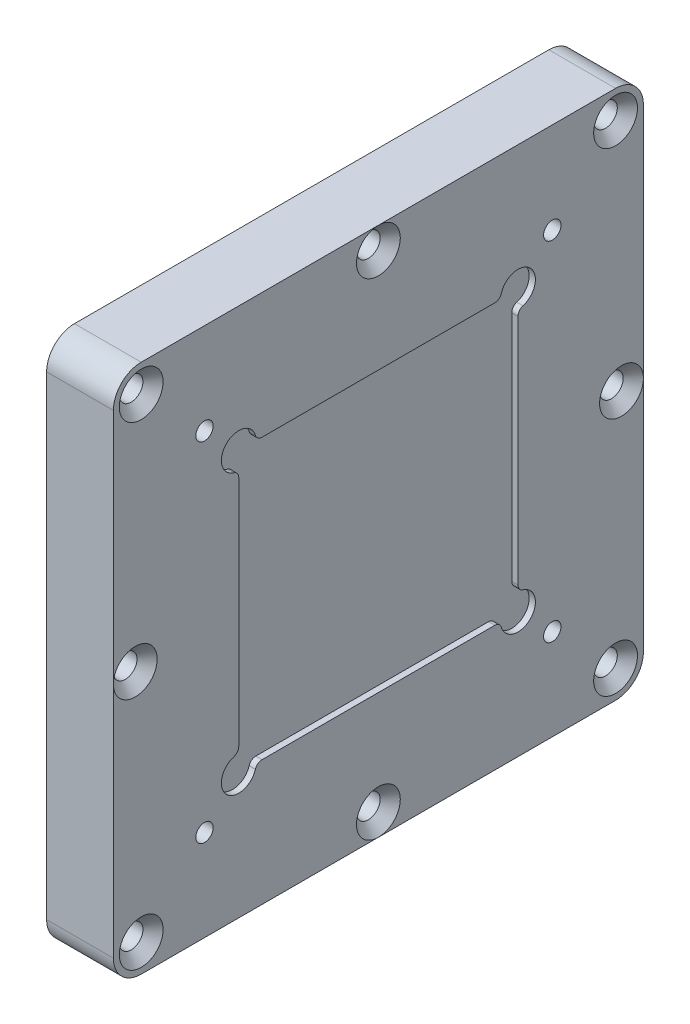
from build123d import *

# Parameters (mm, degrees)
BOSS_EXTRUDE1_DEPTH                             = 9.6
CUT_EXTRUDE1_DEPTH                              = 0.9
FILLET1_R                                       = 1
CSK_FOR_M3_FLAT_HEAD_MACHINE_SCREW1_D           = 3.4
CSK_FOR_M3_FLAT_HEAD_MACHINE_SCREW1_CSINK_D     = 6.3
CSK_FOR_M3_FLAT_HEAD_MACHINE_SCREW1_CSINK_ANGLE = 90
M3X0_5_TAPPED_HOLE1_D                           = 2.5
M3X0_5_TAPPED_HOLE1_DEPTH                       = 7.62
M3X0_5_TAPPED_HOLE1_TIP                         = 0.751075774
M3X0_5_TAPPED_HOLE2_D                           = 2.5
M3X0_5_TAPPED_HOLE2_DEPTH                       = 5.08
M3X0_5_TAPPED_HOLE2_TIP                         = 0.751075774
CUT_EXTRUDE2_DEPTH                              = 6
CHAMFER1_SIZE                                   = 4
FILLET2_R                                       = 1.6


with BuildPart() as part:
    # Sketch2 → Boss-Extrude1 (new body)
    with BuildSketch(Plane(origin=(0, 0, 0), x_dir=(0, 0, -1), z_dir=(1, 0, 0))):
        with BuildLine():
            Line((-34.1, -38.1), (34.1, -38.1))
            ThreePointArc((34.1, -38.1), (36.928427125, -36.928427125), (38.1, -34.1))
            Line((38.1, -34.1), (38.1, 34.1))
            ThreePointArc((38.1, 34.1), (36.928427125, 36.928427125), (34.1, 38.1))
            Line((34.1, 38.1), (-34.1, 38.1))
            ThreePointArc((-34.1, 38.1), (-36.928427125, 36.928427125), (-38.1, 34.1))
            Line((-38.1, 34.1), (-38.1, -34.1))
            ThreePointArc((-38.1, -34.1), (-36.928427125, -36.928427125), (-34.1, -38.1))
        make_face()
    extrude(amount=BOSS_EXTRUDE1_DEPTH)

    # Sketch24 → Cut-Extrude1 (cut)
    with BuildSketch(Plane(origin=(9.6, 0, 0), x_dir=(0, 0, -1), z_dir=(1, 0, 0))):
        with BuildLine():
            ThreePointArc((-20.075, -17.575), (-21.842766953, -21.842766953), (-17.575, -20.075))
            Line((-17.575, -20.075), (17.575, -20.075))
            ThreePointArc((17.575, -20.075), (21.842766953, -21.842766953), (20.075, -17.575))
            Line((20.075, -17.575), (20.075, 17.575))
            ThreePointArc((20.075, 17.575), (21.842766953, 21.842766953), (17.575, 20.075))
            Line((17.575, 20.075), (-17.575, 20.075))
            ThreePointArc((-17.575, 20.075), (-21.842766953, 21.842766953), (-20.075, 17.575))
            Line((-20.075, 17.575), (-20.075, -17.575))
        make_face()
    extrude(amount=-CUT_EXTRUDE1_DEPTH, mode=Mode.SUBTRACT)

    # Fillet1
    fillet1_edges = [part.edges().sort_by_distance(p)[0] for p in [
        (9.15, -20.075, 17.575),
        (9.15, -17.575, 20.075),
        (9.15, -17.575, -20.075),
        (9.15, -20.075, -17.575),
        (9.15, 17.575, -20.075),
        (9.15, 20.075, -17.575),
        (9.15, 20.075, 17.575),
        (9.15, 17.575, 20.075),
    ]]
    fillet(fillet1_edges, radius=FILLET1_R)

    # CSK for M3 Flat Head Machine Screw1 (through all)
    with Locations(Plane(origin=(9.6, 0, 0), x_dir=(0, 0, 1), z_dir=(1, 0, 0))):
        with Locations((-34.100008, -34.1), (34.1, -34.1), (34.1, 34.1), (-34.100008, 34.1), (0, -34.94999995), (34.95, 0), (0, 34.95), (-34.95, 0)):
            CounterSinkHole(CSK_FOR_M3_FLAT_HEAD_MACHINE_SCREW1_D / 2, CSK_FOR_M3_FLAT_HEAD_MACHINE_SCREW1_CSINK_D / 2, counter_sink_angle=CSK_FOR_M3_FLAT_HEAD_MACHINE_SCREW1_CSINK_ANGLE)

    # M3x0.5 Tapped Hole1
    with Locations(Plane(origin=(9.6, 0, 0), x_dir=(0, 0, -1), z_dir=(1, 0, 0))):
        with Locations((-25, 25), (25, 25), (25, -25), (-25, -25)):
            Hole(M3X0_5_TAPPED_HOLE1_D / 2, depth=M3X0_5_TAPPED_HOLE1_DEPTH)
            with Locations((0, 0, -(M3X0_5_TAPPED_HOLE1_DEPTH + M3X0_5_TAPPED_HOLE1_TIP / 2))):  # 118° drill point
                Cone(0, M3X0_5_TAPPED_HOLE1_D / 2, M3X0_5_TAPPED_HOLE1_TIP, mode=Mode.SUBTRACT)

    # M3x0.5 Tapped Hole2
    with Locations(Plane.ZY):
        with Locations((-16, 16), (16, 16), (16, -16), (-16, -16)):
            Hole(M3X0_5_TAPPED_HOLE2_D / 2, depth=M3X0_5_TAPPED_HOLE2_DEPTH)
            with Locations((0, 0, -(M3X0_5_TAPPED_HOLE2_DEPTH + M3X0_5_TAPPED_HOLE2_TIP / 2))):  # 118° drill point
                Cone(0, M3X0_5_TAPPED_HOLE2_D / 2, M3X0_5_TAPPED_HOLE2_TIP, mode=Mode.SUBTRACT)

    # Sketch37 → Cut-Extrude2 (cut)
    with BuildSketch(Plane.ZY):
        Polygon((-1.75, 25.4), (-1.75, 1.75), (-25.4, 1.75), (-25.4, -1.75), (-1.75, -1.75), (-1.75, -25.4), (1.75, -25.4), (1.75, -1.75), (25.4, -1.75), (25.4, 1.75), (1.75, 1.75), (1.75, 25.4), align=None)
        Polygon((-2.75, 2.75), (-2.75, 25.4), (-6.75, 25.4), (-6.75, 6.75), (-25.4, 6.75), (-25.4, 2.75), align=None)
        Polygon((6.75, 25.4), (2.75, 25.4), (2.75, 2.75), (25.4, 2.75), (25.4, 6.75), (6.75, 6.75), align=None)
        Polygon((-2.75, -2.75), (-25.4, -2.75), (-25.4, -6.75), (-6.75, -6.75), (-6.75, -25.4), (-2.75, -25.4), align=None)
        Polygon((-7.75, 7.75), (-7.75, 25.4), (-11.75, 25.4), (-11.75, 11.75), (-25.4, 11.75), (-25.4, 7.75), align=None)
        Polygon((11.75, 25.4), (7.75, 25.4), (7.75, 7.75), (25.4, 7.75), (25.4, 11.75), (11.75, 11.75), align=None)
        Polygon((-7.75, -7.75), (-25.4, -7.75), (-25.4, -11.75), (-11.75, -11.75), (-11.75, -25.4), (-7.75, -25.4), align=None)
        Polygon((25.4, -6.75), (25.4, -2.75), (2.75, -2.75), (2.75, -25.4), (6.75, -25.4), (6.75, -6.75), align=None)
        Polygon((-12.75, 19.75), (-12.75, 25.4), (-20.450252532, 25.4), (-25.4, 20.450252532), (-25.4, 12.75), (-19.75, 12.75), (-19.75, 19.75), align=None)
        Polygon((20.450252532, 25.4), (12.75, 25.4), (12.75, 19.75), (19.75, 19.75), (19.75, 12.75), (25.4, 12.75), (25.4, 20.450252532), align=None)
        Polygon((-19.75, -12.75), (-25.4, -12.75), (-25.4, -20.450252532), (-20.450252532, -25.4), (-12.75, -25.4), (-12.75, -19.75), (-19.75, -19.75), align=None)
        Polygon((25.4, -11.75), (25.4, -7.75), (7.75, -7.75), (7.75, -25.4), (11.75, -25.4), (11.75, -11.75), align=None)
        Polygon((25.4, -20.450252532), (25.4, -12.75), (19.75, -12.75), (19.75, -19.75), (12.75, -19.75), (12.75, -25.4), (20.450252532, -25.4), align=None)
    extrude(amount=-CUT_EXTRUDE2_DEPTH, mode=Mode.SUBTRACT)

    # Chamfer1
    chamfer1_edges = [part.edges().sort_by_distance(p)[0] for p in [
        (6, 9.75, -25.4),
        (6, 4.75, -25.4),
        (6, 0, -25.4),
        (6, -4.75, -25.4),
        (6, -9.75, -25.4),
        (6, -25.4, -9.75),
        (6, -25.4, -4.75),
        (6, -25.4, 0),
        (6, -25.4, 4.75),
        (6, -25.4, 9.75),
        (6, -9.75, 25.4),
        (6, -4.75, 25.4),
        (6, 0, 25.4),
        (6, 4.75, 25.4),
        (6, 9.75, 25.4),
        (6, 25.4, 9.75),
        (6, 25.4, 4.75),
        (6, 25.4, 0),
        (6, 25.4, -4.75),
        (6, 25.4, -9.75),
    ]]
    chamfer(chamfer1_edges, length=CHAMFER1_SIZE)

    # Fillet2
    fillet2_edges = [part.edges().sort_by_distance(p)[0] for p in [
        (1, 25.4, -7.75),
        (4, 23.4, -7.75),
        (4, 23.4, -2.75),
        (1, 25.4, -2.75),
        (1, 25.4, 1.75),
        (4, 23.4, 1.75),
        (4, 23.4, 6.75),
        (1, 25.4, 6.75),
        (1, 25.4, 11.75),
        (4, 23.4, 11.75),
        (4, 23.4, 7.75),
        (1, 25.4, 7.75),
        (4, 23.4, 2.75),
        (1, 25.4, 2.75),
        (4, 23.4, -1.75),
        (1, 25.4, -1.75),
        (4, 23.4, -6.75),
        (1, 25.4, -6.75),
        (4, 23.4, -11.75),
        (1, 25.4, -11.75),
        (3, 20.450252532, 25.4),
        (3, 25.4, 20.450252532),
        (3, 25.4, 12.75),
        (3, 19.75, 12.75),
        (3, -19.75, -12.75),
        (3, -12.75, 19.75),
        (3, -19.75, 12.75),
        (3, -25.4, 12.75),
        (3, -25.4, 20.450252532),
        (3, -20.450252532, 25.4),
        (3, -12.75, 25.4),
        (4, -6.75, 23.4),
        (1, -6.75, 25.4),
        (4, -1.75, 23.4),
        (1, -1.75, 25.4),
        (4, 2.75, 23.4),
        (1, 2.75, 25.4),
        (4, 7.75, 23.4),
        (1, 7.75, 25.4),
        (3, 12.75, 25.4),
        (4, 11.75, 23.4),
        (1, 11.75, 25.4),
        (4, 6.75, 23.4),
        (1, 6.75, 25.4),
        (4, 1.75, 23.4),
        (1, 1.75, 25.4),
        (4, -2.75, 23.4),
        (1, -2.75, 25.4),
        (4, -7.75, 23.4),
        (1, -7.75, 25.4),
        (4, -11.75, 23.4),
        (1, -11.75, 25.4),
        (1, -25.4, 11.75),
        (4, -23.4, 11.75),
        (1, -25.4, 7.75),
        (4, -23.4, 7.75),
        (1, -25.4, 6.75),
        (4, -23.4, 6.75),
        (1, -25.4, 2.75),
        (4, -23.4, 2.75),
        (3, -25.4, -12.75),
        (3, -25.4, -20.450252532),
        (3, -20.450252532, -25.4),
        (3, -12.75, -25.4),
        (3, -12.75, -19.75),
        (3, 12.75, -19.75),
        (3, 19.75, -12.75),
        (3, 25.4, -12.75),
        (3, 25.4, -20.450252532),
        (3, 20.450252532, -25.4),
        (3, 12.75, -25.4),
        (4, 7.75, -23.4),
        (1, 7.75, -25.4),
        (4, 2.75, -23.4),
        (1, 2.75, -25.4),
        (1, -1.75, -25.4),
        (4, -1.75, -23.4),
        (4, -7.75, -23.4),
        (4, -2.75, -23.4),
        (4, 1.75, -23.4),
        (4, 6.75, -23.4),
        (4, 11.75, -23.4),
        (1, 11.75, -25.4),
        (1, 6.75, -25.4),
        (1, 1.75, -25.4),
        (1, -2.75, -25.4),
        (1, -7.75, -25.4),
        (1, -11.75, -25.4),
        (4, -11.75, -23.4),
        (4, -23.4, -7.75),
        (4, -23.4, -11.75),
        (4, -23.4, -6.75),
        (4, -23.4, -2.75),
        (4, -23.4, 1.75),
        (4, -23.4, -1.75),
        (1, -25.4, -1.75),
        (1, -25.4, 1.75),
        (1, -25.4, -2.75),
        (1, -25.4, -6.75),
        (1, -25.4, -7.75),
        (1, -25.4, -11.75),
        (3, -19.75, -19.75),
        (3, -11.75, -11.75),
        (3, -6.75, -6.75),
        (3, -7.75, -7.75),
        (3, -2.75, -2.75),
        (3, 19.75, -19.75),
        (3, 11.75, -11.75),
        (3, 7.75, -7.75),
        (3, 2.75, -2.75),
        (3, 1.75, 1.75),
        (3, 6.75, 6.75),
        (3, 11.75, 11.75),
        (3, 19.75, 19.75),
        (3, 7.75, 7.75),
        (3, 2.75, 2.75),
        (3, 1.75, -1.75),
        (3, -1.75, -1.75),
        (3, -19.75, 19.75),
        (3, -11.75, 11.75),
        (3, -7.75, 7.75),
        (3, -6.75, 6.75),
        (3, -1.75, 1.75),
        (3, -2.75, 2.75),
        (4, -6.75, -23.4),
        (1, -6.75, -25.4),
    ]]
    fillet(fillet2_edges, radius=FILLET2_R)


solid = part.part
